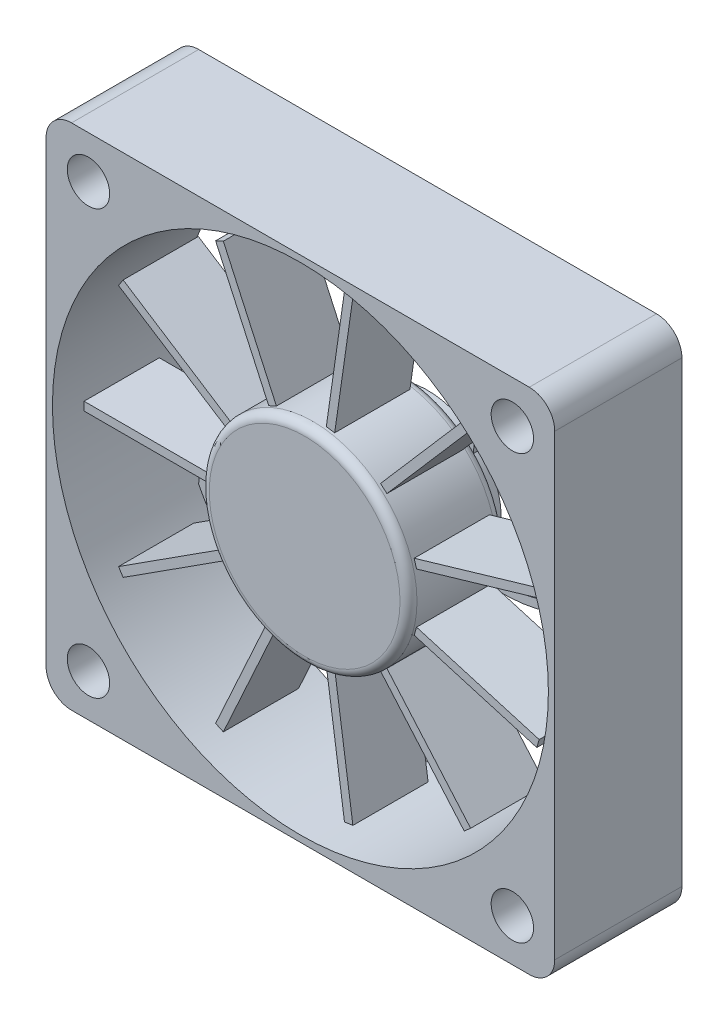
from build123d import *

# Parameters (mm, degrees)
SKETCH1_R           = 29.25
SKETCH1_R_2         = 2.5
BOSS_EXTRUDE1_DEPTH = 15
BOSS_EXTRUDE2_DEPTH = 1
SKETCH3_R           = 2
BOSS_EXTRUDE3_DEPTH = 2
SKETCH4_R           = 12.25
BOSS_EXTRUDE4_DEPTH = 11.5
FILLET1_R           = 1
SKETCH5_W           = 15.076616943
SKETCH5_H           = 8.874738886
BOSS_EXTRUDE5_DEPTH = 0.5
CIRPATTERN3_COUNT   = 11


with BuildPart() as part:
    # Sketch1 → Boss-Extrude1 (new body)
    with BuildSketch(Plane.XY):
        with BuildLine():
            Line((27, -30), (-27, -30))
            ThreePointArc((-27, -30), (-29.121320344, -29.121320344), (-30, -27))
            Line((-30, -27), (-30, 27))
            ThreePointArc((-30, 27), (-29.121320344, 29.121320344), (-27, 30))
            Line((-27, 30), (27, 30))
            ThreePointArc((27, 30), (29.121320344, 29.121320344), (30, 27))
            Line((30, 27), (30, -27))
            ThreePointArc((30, -27), (29.121320344, -29.121320344), (27, -30))
        make_face()
        Circle(SKETCH1_R, mode=Mode.SUBTRACT)
        with Locations((-25, -25)):
            Circle(SKETCH1_R_2, mode=Mode.SUBTRACT)
        with Locations((25, -25)):
            Circle(SKETCH1_R_2, mode=Mode.SUBTRACT)
        with Locations((25, 25)):
            Circle(SKETCH1_R_2, mode=Mode.SUBTRACT)
        with Locations((-25, 25)):
            Circle(SKETCH1_R_2, mode=Mode.SUBTRACT)
    extrude(amount=BOSS_EXTRUDE1_DEPTH)

    # Sketch2 → Boss-Extrude2 (add)
    with BuildSketch(Plane(origin=(0, 0, 0), x_dir=(-1, 0, 0), z_dir=(0, 0, -1))):
        with BuildLine():
            Line((-25.900335781, 22.154072903), (-24.902710863, 22.085192403))
            add(Edge.make_bspline(
                [(-24.902710863, 22.085192403), (-26.28162356, 2.113826336), (-20.227560007, -7.075660435), (-6.740520203, -5.483267909)],
                knots=[0, 0, 0, 0, 0.983104227, 0.983104227, 0.983104227, 0.983104227], degree=3))
            ThreePointArc((-6.740520203, -5.483267909), (-8.68480288, 0.273931558), (-6.381564702, 5.897157919))
            add(Edge.make_bspline(
                [(22.154072903, 25.900335781), (10.621605783, 26.724100711), (0.072755528, 22.899004242), (-3.862517278, 19.232875816), (-5.884498412, 15.501681058), (-6.970258265, 9.958862515), (-6.381564702, 5.897157919)],
                knots=[0, 0, 0, 0.375, 0.5625, 0.6875, 0.8125, 1, 1, 1], degree=2))
            Line((22.154072903, 25.900335781), (22.085192403, 24.902710863))
            add(Edge.make_bspline(
                [(22.085192403, 24.902710863), (2.113826336, 26.28162356), (-7.075660435, 20.227560007), (-5.483267909, 6.740520203)],
                knots=[0, 0, 0, 0, 0.983104227, 0.983104227, 0.983104227, 0.983104227], degree=3))
            ThreePointArc((-5.483267909, 6.740520203), (0.273931558, 8.68480288), (5.897157919, 6.381564702))
            add(Edge.make_bspline(
                [(25.900335781, -22.154072903), (26.724100711, -10.621605783), (22.899004242, -0.072755528), (19.232875816, 3.862517278), (15.501681058, 5.884498412), (9.958862515, 6.970258265), (5.897157919, 6.381564702)],
                knots=[0, 0, 0, 0.375, 0.5625, 0.6875, 0.8125, 1, 1, 1], degree=2))
            Line((25.900335781, -22.154072903), (24.902710863, -22.085192403))
            add(Edge.make_bspline(
                [(24.902710863, -22.085192403), (26.28162356, -2.113826336), (20.227560007, 7.075660435), (6.740520203, 5.483267909)],
                knots=[0, 0, 0, 0, 0.983104227, 0.983104227, 0.983104227, 0.983104227], degree=3))
            ThreePointArc((6.740520203, 5.483267909), (8.68480288, -0.273931558), (6.381564702, -5.897157919))
            add(Edge.make_bspline(
                [(-22.154072903, -25.900335781), (-10.621605783, -26.724100711), (-0.072755528, -22.899004242), (3.862517278, -19.232875816), (5.884498412, -15.501681058), (6.970258265, -9.958862515), (6.381564702, -5.897157919)],
                knots=[0, 0, 0, 0.375, 0.5625, 0.6875, 0.8125, 1, 1, 1], degree=2))
            Line((-22.154072903, -25.900335781), (-22.085192403, -24.902710863))
            add(Edge.make_bspline(
                [(-22.085192403, -24.902710863), (-2.113826336, -26.28162356), (7.075660435, -20.227560007), (5.483267909, -6.740520203)],
                knots=[0, 0, 0, 0, 0.983104227, 0.983104227, 0.983104227, 0.983104227], degree=3))
            ThreePointArc((5.483267909, -6.740520203), (-0.273931558, -8.68480288), (-5.897157919, -6.381564702))
            add(Edge.make_bspline(
                [(-25.900335781, 22.154072903), (-26.724100711, 10.621605783), (-22.899004242, 0.072755528), (-19.232875816, -3.862517278), (-15.501681058, -5.884498412), (-9.958862515, -6.970258265), (-5.897157919, -6.381564702)],
                knots=[0, 0, 0, 0.375, 0.5625, 0.6875, 0.8125, 1, 1, 1], degree=2))
        make_face()
    extrude(amount=-BOSS_EXTRUDE2_DEPTH)

    # Sketch3 → Boss-Extrude3 (add)
    with BuildSketch(Plane.XY.offset(1)):
        Circle(SKETCH3_R)
    extrude(amount=BOSS_EXTRUDE3_DEPTH)

    # Sketch4 → Boss-Extrude4 (add)
    with BuildSketch(Plane.XY.offset(3)):
        Circle(SKETCH4_R)
    extrude(amount=BOSS_EXTRUDE4_DEPTH)

    # Fillet1
    fillet1_edges = [part.edges().sort_by_distance(p)[0] for p in [
        (-12.25, 0, 3),
        (-12.25, 0, 14.5),
    ]]
    fillet(fillet1_edges, radius=FILLET1_R)


with BuildPart() as body_2:
    # Sketch5 → Boss-Extrude5 (new body, symmetric)
    with BuildSketch(Plane(origin=(0, 0, 0), x_dir=(1, 0, 0), z_dir=(0, 1, 0))):
        with Locations((-19.788308472, -8.757695818)):
            Rectangle(SKETCH5_W, SKETCH5_H)
    extrude(amount=BOSS_EXTRUDE5_DEPTH, both=True)


with BuildPart() as cirpattern3_1:
    # CirPattern3: pattern copy
    add(body_2.part.rotate(Axis((0, 0, 0), (0, 0, 1)), 1 * 360 / CIRPATTERN3_COUNT))


with BuildPart() as cirpattern3_2:
    # CirPattern3: pattern copy
    add(body_2.part.rotate(Axis((0, 0, 0), (0, 0, 1)), 2 * 360 / CIRPATTERN3_COUNT))


with BuildPart() as cirpattern3_3:
    # CirPattern3: pattern copy
    add(body_2.part.rotate(Axis((0, 0, 0), (0, 0, 1)), 3 * 360 / CIRPATTERN3_COUNT))


with BuildPart() as cirpattern3_4:
    # CirPattern3: pattern copy
    add(body_2.part.rotate(Axis((0, 0, 0), (0, 0, 1)), 4 * 360 / CIRPATTERN3_COUNT))


with BuildPart() as cirpattern3_5:
    # CirPattern3: pattern copy
    add(body_2.part.rotate(Axis((0, 0, 0), (0, 0, 1)), 5 * 360 / CIRPATTERN3_COUNT))


with BuildPart() as cirpattern3_6:
    # CirPattern3: pattern copy
    add(body_2.part.rotate(Axis((0, 0, 0), (0, 0, 1)), 6 * 360 / CIRPATTERN3_COUNT))


with BuildPart() as cirpattern3_7:
    # CirPattern3: pattern copy
    add(body_2.part.rotate(Axis((0, 0, 0), (0, 0, 1)), 7 * 360 / CIRPATTERN3_COUNT))


with BuildPart() as cirpattern3_8:
    # CirPattern3: pattern copy
    add(body_2.part.rotate(Axis((0, 0, 0), (0, 0, 1)), 8 * 360 / CIRPATTERN3_COUNT))


with BuildPart() as cirpattern3_9:
    # CirPattern3: pattern copy
    add(body_2.part.rotate(Axis((0, 0, 0), (0, 0, 1)), 9 * 360 / CIRPATTERN3_COUNT))


with BuildPart() as cirpattern3_10:
    # CirPattern3: pattern copy
    add(body_2.part.rotate(Axis((0, 0, 0), (0, 0, 1)), 10 * 360 / CIRPATTERN3_COUNT))


solid = Compound([part.part, body_2.part, cirpattern3_1.part, cirpattern3_2.part, cirpattern3_3.part, cirpattern3_4.part, cirpattern3_5.part, cirpattern3_6.part, cirpattern3_7.part, cirpattern3_8.part, cirpattern3_9.part, cirpattern3_10.part])
